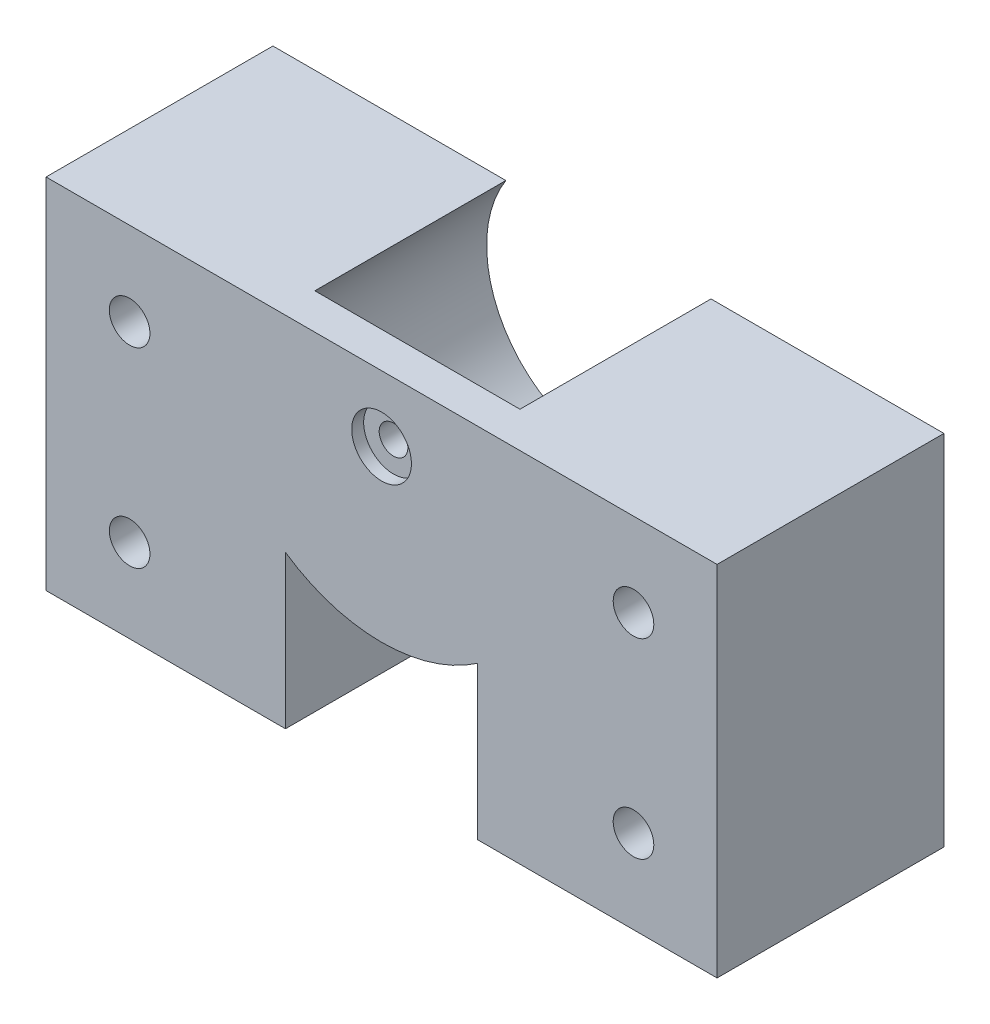
from build123d import *

# Parameters (mm, degrees)
BOSS_EXTRUDE1_DEPTH = 16
SKETCH3_W           = 56.2
SKETCH3_H           = 30
BOSS_EXTRUDE2_DEPTH = 3
SKETCH4_R           = 1.7
SKETCH4_R_2         = 1.2
CUT_EXTRUDE2_DEPTH  = 19
CUT_EXTRUDE3_DEPTH  = 16
CUT_EXTRUDE6_REACH  = 21
SKETCH10_R          = 2.5
CUT_EXTRUDE7_DEPTH  = 1


with BuildPart() as part:
    # Sketch1 → Boss-Extrude1 (new body)
    with BuildSketch(Plane.XY):
        with BuildLine():
            Line((19.509889407, 0), (0, 0))
            Line((0, 0), (0, -30))
            Line((0, -30), (56.2, -30))
            Line((56.2, -30), (56.2, 0))
            Line((56.2, 0), (36.690110593, 0))
            Line((36.690110593, 0), (35.825930365, 0))
            ThreePointArc((35.825930365, 0), (34.325930365, -1.5), (35.825930365, -3))
            Line((35.825930365, -3), (37.988882647, -3))
            ThreePointArc((37.988882647, -3), (26.465465751, -15.568182447), (19.509889407, 0))
        make_face()
    extrude(amount=BOSS_EXTRUDE1_DEPTH)

    # Sketch3 → Boss-Extrude2 (add)
    with BuildSketch(Plane.XY.offset(16)):
        with Locations((28.1, -15)):
            Rectangle(SKETCH3_W, SKETCH3_H)
    extrude(amount=BOSS_EXTRUDE2_DEPTH)

    # Sketch4 → Cut-Extrude2 (cut)
    with BuildSketch(Plane(origin=(0, 0, 0), x_dir=(-1, 0, 0), z_dir=(0, 0, -1))):
        with Locations((-49.2, -7)):
            Circle(SKETCH4_R)
        with Locations((-7, -7)):
            Circle(SKETCH4_R)
        with Locations((-7, -23)):
            Circle(SKETCH4_R)
        with Locations((-49.2, -23)):
            Circle(SKETCH4_R)
        with Locations((-28.1, -5.5)):
            Circle(SKETCH4_R_2)
    extrude(amount=-CUT_EXTRUDE2_DEPTH, mode=Mode.SUBTRACT)

    # Sketch5 → Cut-Extrude3 (cut)
    with BuildSketch(Plane(origin=(0, 0, 0), x_dir=(-1, 0, 0), z_dir=(0, 0, -1))):
        with BuildLine():
            Line((-19.509889407, 0), (-36.690110593, 0))
            ThreePointArc((-36.690110593, 0), (-28.1, -15.7), (-19.509889407, 0))
        make_face()
    extrude(amount=-CUT_EXTRUDE3_DEPTH, mode=Mode.SUBTRACT)

    # Sketch9 → Cut-Extrude6 (cut, up to next)
    with BuildSketch(Plane.XY, mode=Mode.PRIVATE) as cut_extrude6_sk1:
        with BuildLine():
            Line((36.15, -30), (36.15, -17.197756195))
            ThreePointArc((36.15, -17.197756195), (28.1, -19.7), (20.05, -17.197756195))
            Line((20.05, -17.197756195), (20.05, -30))
            Line((20.05, -30), (36.15, -30))
        make_face()
    cut_extrude6_tool1 = extrude(cut_extrude6_sk1.sketch, amount=CUT_EXTRUDE6_REACH, mode=Mode.PRIVATE) & part.part
    add(cut_extrude6_tool1.solids().sort_by_distance((28.1, -24.424534, 0))[0], mode=Mode.SUBTRACT)

    # Sketch10 → Cut-Extrude7 (cut)
    with BuildSketch(Plane.XY.offset(19)):
        with Locations((28.1, -5.5)):
            Circle(SKETCH10_R)
    extrude(amount=-CUT_EXTRUDE7_DEPTH, mode=Mode.SUBTRACT)


solid = part.part
